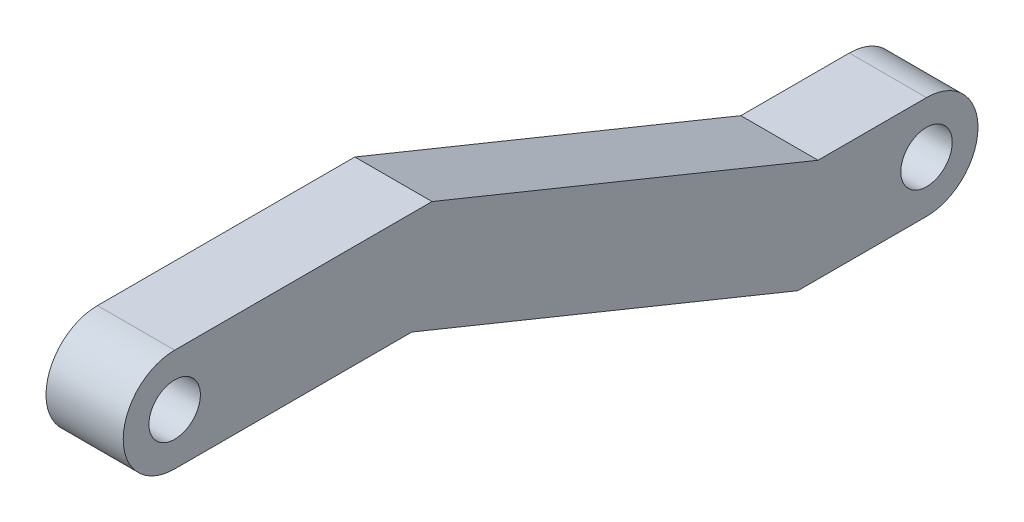
from build123d import *

# Parameters (mm, degrees)
SKETCH2_R           = 1
BOSS_EXTRUDE1_DEPTH = 3


with BuildPart() as part:
    # Sketch2 → Boss-Extrude1 (new body)
    with BuildSketch(Plane(origin=(0, 0, 0), x_dir=(0, 0, -1), z_dir=(1, 0, 0))):
        with BuildLine():
            Line((19.216665357, -6.109306765), (15, -6.109306765))
            Line((15, -6.109306765), (0, 0))
            Line((0, 0), (-10.001460368, 0))
            ThreePointArc((-10.001460368, 0), (-12.001460368, -2), (-10.001460368, -4))
            Line((-10.001460368, -4), (-0.783334643, -4))
            Line((-0.783334643, -4), (14.216665357, -10.109306765))
            Line((14.216665357, -10.109306765), (19.216665357, -10.109306765))
            ThreePointArc((19.216665357, -10.109306765), (21.216665357, -8.109306765), (19.216665357, -6.109306765))
        make_face()
        with Locations((19.216665357, -8.109306765)):
            Circle(SKETCH2_R, mode=Mode.SUBTRACT)
        with Locations((-10.001460368, -2)):
            Circle(SKETCH2_R, mode=Mode.SUBTRACT)
    extrude(amount=BOSS_EXTRUDE1_DEPTH)


solid = part.part
